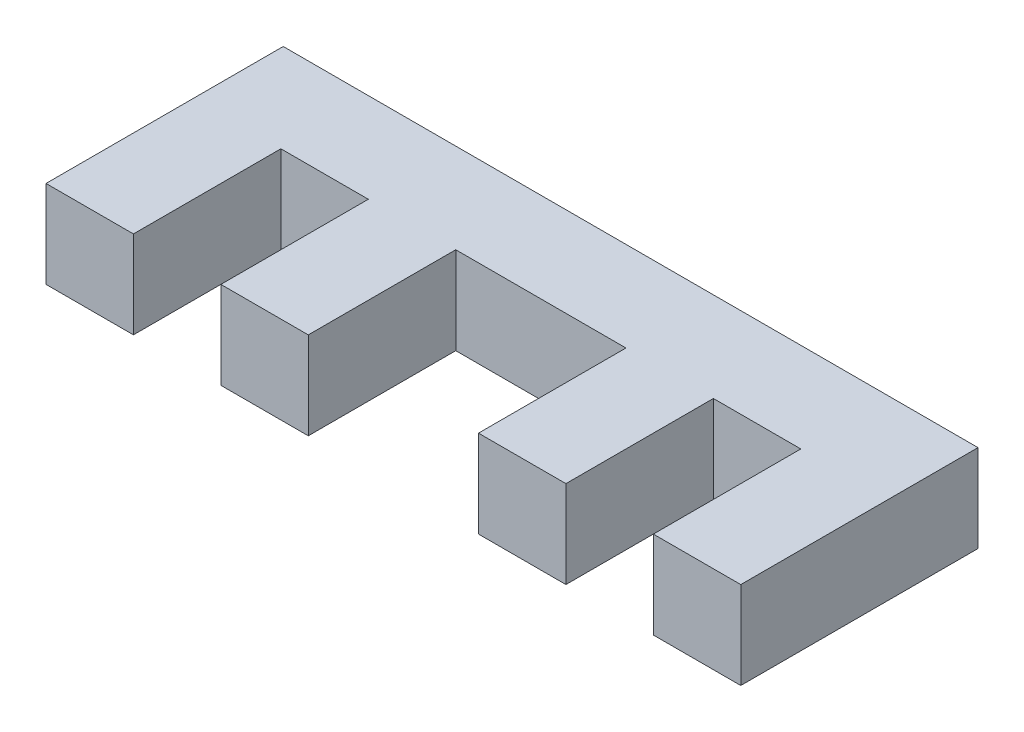
from build123d import *

# Parameters (mm, degrees)
BOSS_EXTRUDE1_DEPTH = 3.175


with BuildPart() as part:
    # Sketch1 → Boss-Extrude1 (new body)
    with BuildSketch(Plane(origin=(0, 0, 0), x_dir=(1, 0, 0), z_dir=(0, 1, 0))):
        Polygon((0, 0), (3.175, 0), (3.175, 5.355166667), (6.35, 5.355166667), (6.35, 0), (9.525, 0), (9.525, 5.355166667), (15.705666667, 5.355166667), (15.705666667, 0), (18.880666667, 0), (18.880666667, 5.355166667), (22.055666667, 5.355166667), (22.055666667, 0), (25.230666667, 0), (25.230666667, 8.614833333), (0, 8.614833333), align=None)
    extrude(amount=BOSS_EXTRUDE1_DEPTH)


solid = part.part
